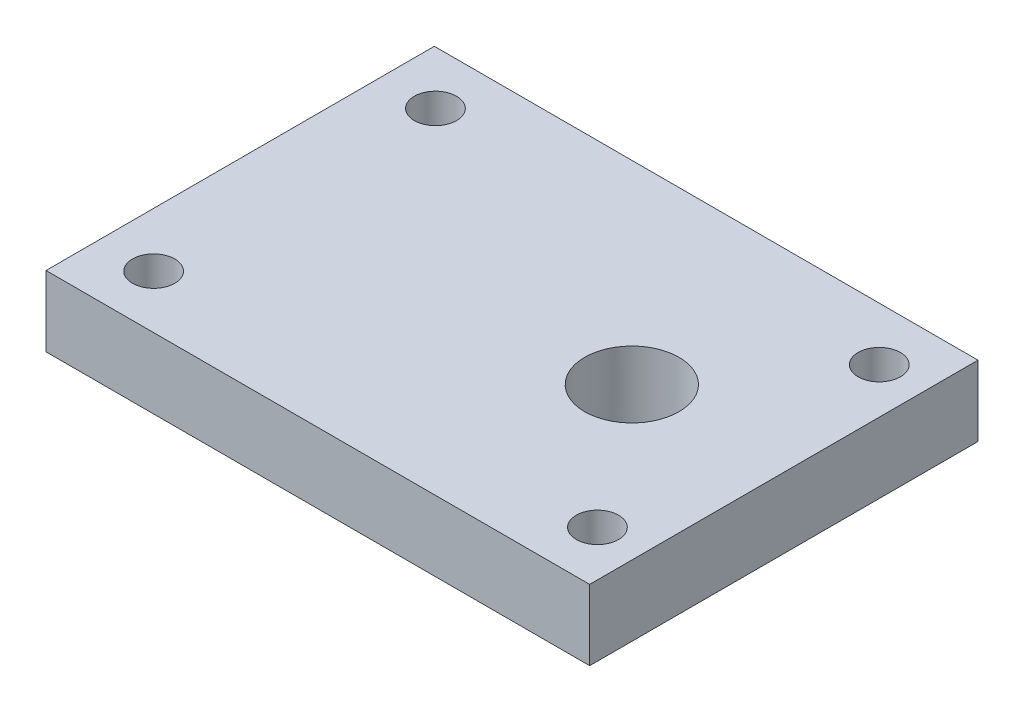
from build123d import *

# Parameters (mm, degrees)
SKETCH1_W           = 49
SKETCH1_H           = 35
SKETCH1_R           = 1.905
BOSS_EXTRUDE1_DEPTH = 6.35
SKETCH2_R           = 4.25
CUT_EXTRUDE1_DEPTH  = 6.35


with BuildPart() as part:
    # Sketch1 → Boss-Extrude1 (new body)
    with BuildSketch(Plane(origin=(0, 0, 0), x_dir=(1, 0, 0), z_dir=(0, 1, 0))):
        Rectangle(SKETCH1_W, SKETCH1_H)
        with Locations((-19.6, 12.7)):
            Circle(SKETCH1_R, mode=Mode.SUBTRACT)
        with Locations((20.4, 12.7)):
            Circle(SKETCH1_R, mode=Mode.SUBTRACT)
        with Locations((-19.6, -12.7)):
            Circle(SKETCH1_R, mode=Mode.SUBTRACT)
        with Locations((20.4, -12.7)):
            Circle(SKETCH1_R, mode=Mode.SUBTRACT)
    extrude(amount=BOSS_EXTRUDE1_DEPTH)

    # Sketch2 → Cut-Extrude1 (cut)
    with BuildSketch(Plane(origin=(0, 6.35, 0), x_dir=(1, 0, 0), z_dir=(0, 1, 0))):
        with Locations((10.8, 0)):
            Circle(SKETCH2_R)
    extrude(amount=-CUT_EXTRUDE1_DEPTH, mode=Mode.SUBTRACT)


solid = part.part
